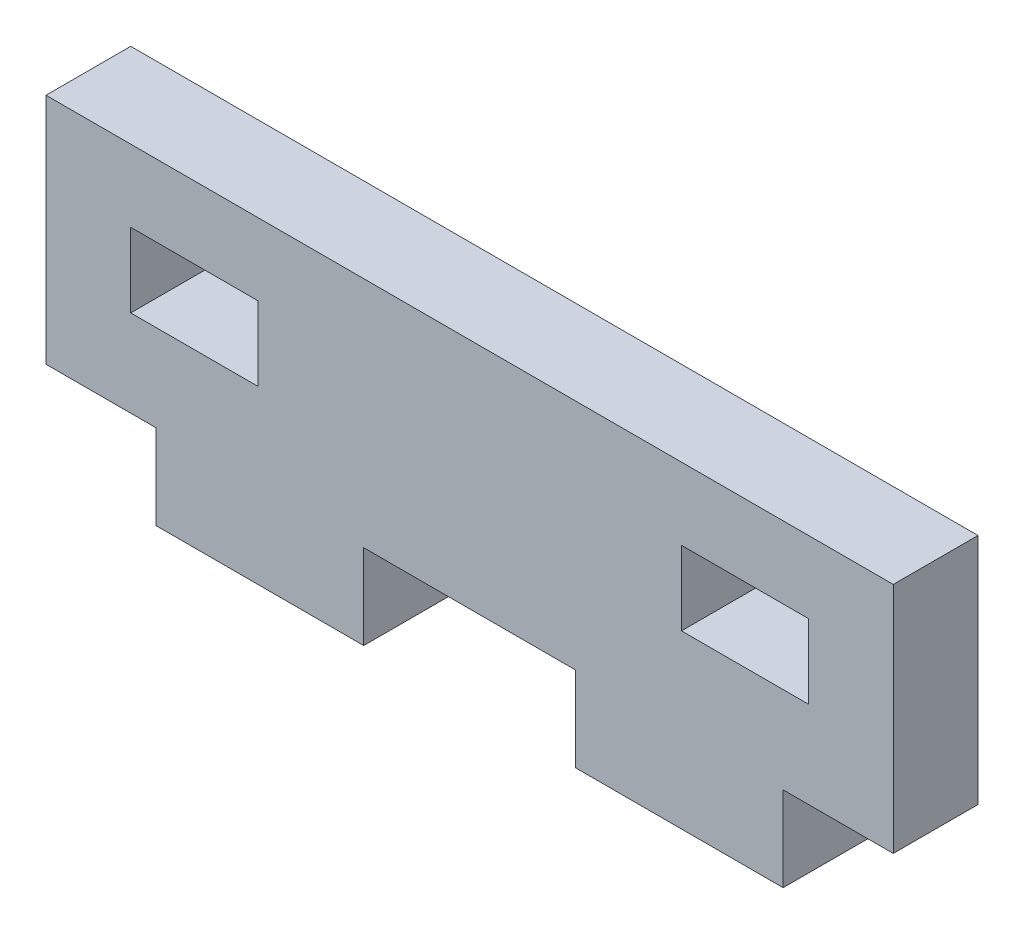
from build123d import *

# Parameters (mm, degrees)
AUFSATZ_LINEAR_AUSTRAGEN1_DEPTH = 4
SCHNITT_LINEAR_AUSTRAGEN1_REACH = 6
SKIZZE3_W                       = 2.7
SKIZZE3_H                       = 4
SKIZZE3_W_2                     = 10
SCHNITT_LINEAR_AUSTRAGEN2_REACH = 6
SKIZZE4_W                       = 6
SKIZZE4_H                       = 3.5


with BuildPart() as part:
    # Skizze2 → Aufsatz-Linear austragen1 (new body)
    with BuildSketch(Plane.XY):
        Polygon((0, 0), (0, 4), (-2.5, 4), (-2.5, 15), (37.5, 15), (37.5, 4), (35, 4), (35, 0), align=None)
    extrude(amount=AUFSATZ_LINEAR_AUSTRAGEN1_DEPTH)

    # Skizze3 → Schnitt-Linear austragen1 (cut, up to next)
    with BuildSketch(Plane.XY.offset(4), mode=Mode.PRIVATE) as schnitt_linear_austragen1_sk1:
        with Locations((1.35, 2)):
            Rectangle(SKIZZE3_W, SKIZZE3_H)
    schnitt_linear_austragen1_tool1 = extrude(schnitt_linear_austragen1_sk1.sketch, amount=-SCHNITT_LINEAR_AUSTRAGEN1_REACH, mode=Mode.PRIVATE) & part.part
    add(schnitt_linear_austragen1_tool1.solids().sort_by_distance((1.35, 2, 4))[0], mode=Mode.SUBTRACT)
    # Skizze3 → Schnitt-Linear austragen1 (cut, up to next)
    with BuildSketch(Plane.XY.offset(4), mode=Mode.PRIVATE) as schnitt_linear_austragen1_sk2:
        with Locations((17.5, 2)):
            Rectangle(SKIZZE3_W_2, SKIZZE3_H)
    schnitt_linear_austragen1_tool2 = extrude(schnitt_linear_austragen1_sk2.sketch, amount=-SCHNITT_LINEAR_AUSTRAGEN1_REACH, mode=Mode.PRIVATE) & part.part
    add(schnitt_linear_austragen1_tool2.solids().sort_by_distance((17.5, 2, 4))[0], mode=Mode.SUBTRACT)
    # Skizze3 → Schnitt-Linear austragen1 (cut, up to next)
    with BuildSketch(Plane.XY.offset(4), mode=Mode.PRIVATE) as schnitt_linear_austragen1_sk3:
        with Locations((33.65, 2)):
            Rectangle(SKIZZE3_W, SKIZZE3_H)
    schnitt_linear_austragen1_tool3 = extrude(schnitt_linear_austragen1_sk3.sketch, amount=-SCHNITT_LINEAR_AUSTRAGEN1_REACH, mode=Mode.PRIVATE) & part.part
    add(schnitt_linear_austragen1_tool3.solids().sort_by_distance((33.65, 2, 4))[0], mode=Mode.SUBTRACT)

    # Skizze4 → Schnitt-Linear austragen2 (cut, up to next)
    with BuildSketch(Plane.XY.offset(4), mode=Mode.PRIVATE) as schnitt_linear_austragen2_sk1:
        with Locations((4.5, 9.85)):
            Rectangle(SKIZZE4_W, SKIZZE4_H)
    schnitt_linear_austragen2_tool1 = extrude(schnitt_linear_austragen2_sk1.sketch, amount=-SCHNITT_LINEAR_AUSTRAGEN2_REACH, mode=Mode.PRIVATE) & part.part
    add(schnitt_linear_austragen2_tool1.solids().sort_by_distance((4.5, 9.85, 4))[0], mode=Mode.SUBTRACT)
    # Skizze4 → Schnitt-Linear austragen2 (cut, up to next)
    with BuildSketch(Plane.XY.offset(4), mode=Mode.PRIVATE) as schnitt_linear_austragen2_sk2:
        with Locations((30.5, 9.85)):
            Rectangle(SKIZZE4_W, SKIZZE4_H)
    schnitt_linear_austragen2_tool2 = extrude(schnitt_linear_austragen2_sk2.sketch, amount=-SCHNITT_LINEAR_AUSTRAGEN2_REACH, mode=Mode.PRIVATE) & part.part
    add(schnitt_linear_austragen2_tool2.solids().sort_by_distance((30.5, 9.85, 4))[0], mode=Mode.SUBTRACT)


solid = part.part
